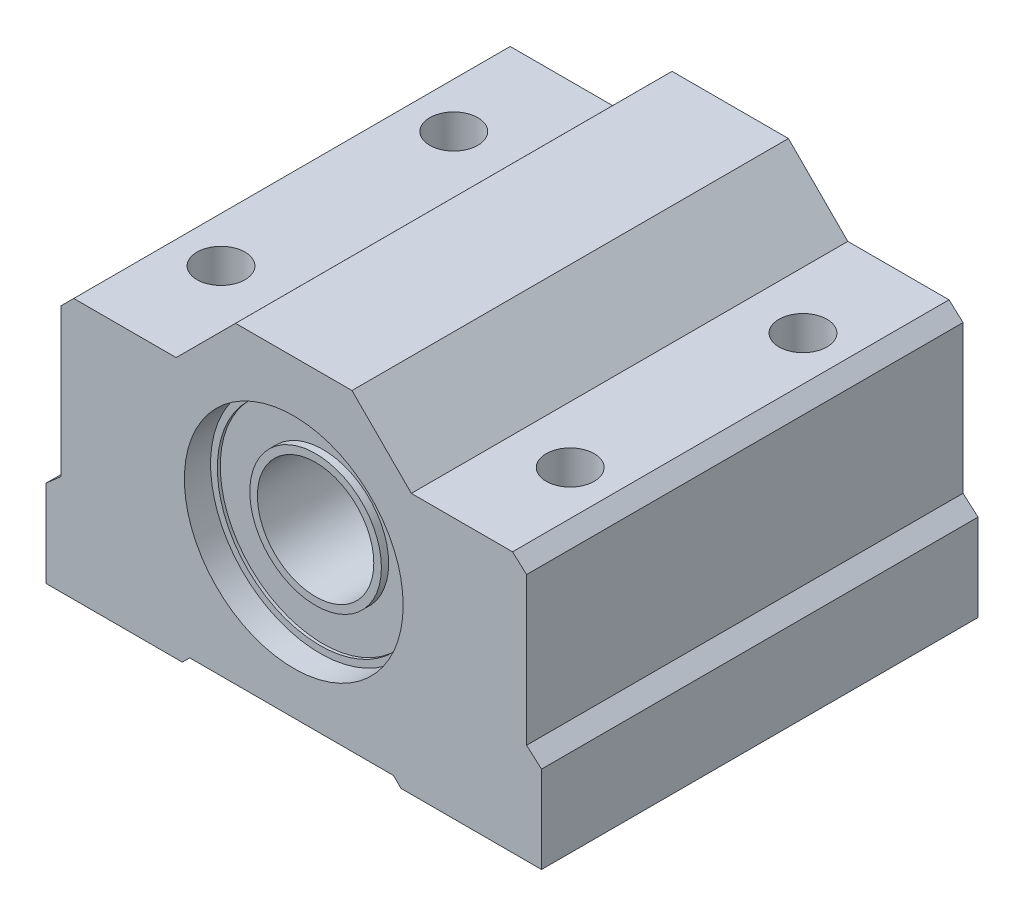
from build123d import *

# Parameters (mm, degrees)
ESQUISSE1_R             = 7.519017315
BOSS_EXTRU_1_DEPTH      = 30
ESQUISSE1_3_R           = 7.051788316
ESQUISSE1_3_R_2         = 4.523392982
BOSS_EXTRU_2_DEPTH      = 28
ESQUISSE1_4_R           = 7.519017315
ESQUISSE1_4_R_2         = 7.051788316
BOSS_EXTRU_3_DEPTH      = 30
ESQUISSE1_5_R           = 4.523392982
ESQUISSE1_5_R_2         = 4
BOSS_EXTRU_4_DEPTH      = 28.5
ESQUISSE1_6_R           = 4.523392982
ESQUISSE1_6_R_2         = 4
ENL_V_MAT_EXTRU_1_DEPTH = 1.5
ESQUISSE1_7_R           = 7.051788316
ESQUISSE1_7_R_2         = 4.523392982
ENL_V_MAT_EXTRU_2_DEPTH = 2
ESQUISSE1_8_R           = 7.519017315
ESQUISSE1_8_R_2         = 7.051788316
ENL_V_MAT_EXTRU_3_DEPTH = 1.8
ENL_V_START             = -30
ESQUISSE1_9_R           = 7.519017315
ESQUISSE1_9_R_2         = 7.051788316
ENL_V_MAT_EXTRU_4_DEPTH = 1.8
ESQUISSE2_R             = 1.65
ENL_V_MAT_EXTRU_5_DEPTH = 21.8


with BuildPart() as part:
    # Esquisse1 → Boss.-Extru.1 (new body)
    with BuildSketch(Plane.XY):
        Polygon((-15.997216081, -4.089203195), (-17.03, -5.004453984), (-17.03, -10.973805396), (-7.66267479, -10.973805396), (-7.153229177, -10.464359784), (6.857616233, -10.464359784), (7.367061846, -10.973805396), (17.03, -10.973805396), (17.03, -4.995255883), (16.002783919, -4.089203195), (16.002783919, 6.07141612), (15.037454618, 6.944265115), (8.081929489, 6.944265115), (4, 11.026194604), (-4, 11.026194604), (-8.083891517, 6.944265115), (-15.124367087, 6.944265115), (-15.997216081, 6.07141612), align=None)
        Circle(ESQUISSE1_R, mode=Mode.SUBTRACT)
    extrude(amount=-BOSS_EXTRU_1_DEPTH)



with BuildPart() as body_2:
    # Esquisse1_3 → Boss.-Extru.2 (new body)
    with BuildSketch(Plane.XY):
        Circle(ESQUISSE1_3_R)
        Circle(ESQUISSE1_3_R_2, mode=Mode.SUBTRACT)
    extrude(amount=-BOSS_EXTRU_2_DEPTH)


with BuildPart() as part_1:
    add(part.part)

    add(body_2.part)  # Boss.-Extru.3 merges body 2
    # Esquisse1_4 → Boss.-Extru.3 (add)
    with BuildSketch(Plane.XY):
        Circle(ESQUISSE1_4_R)
        Circle(ESQUISSE1_4_R_2, mode=Mode.SUBTRACT)
    extrude(amount=-BOSS_EXTRU_3_DEPTH)

    # Esquisse1_5 → Boss.-Extru.4 (add)
    with BuildSketch(Plane.XY):
        Circle(ESQUISSE1_5_R)
        Circle(ESQUISSE1_5_R_2, mode=Mode.SUBTRACT)
    extrude(amount=-BOSS_EXTRU_4_DEPTH)

    # Esquisse1_6 → Enl_v. mat.-Extru.1 (cut)
    with BuildSketch(Plane.XY):
        Circle(ESQUISSE1_6_R)
        Circle(ESQUISSE1_6_R_2, mode=Mode.SUBTRACT)
    extrude(amount=-ENL_V_MAT_EXTRU_1_DEPTH, mode=Mode.SUBTRACT)

    # Esquisse1_7 → Enl_v. mat.-Extru.2 (cut)
    with BuildSketch(Plane.XY):
        Circle(ESQUISSE1_7_R)
        Circle(ESQUISSE1_7_R_2, mode=Mode.SUBTRACT)
    extrude(amount=-ENL_V_MAT_EXTRU_2_DEPTH, mode=Mode.SUBTRACT)

    # Esquisse1_8 → Enl_v. mat.-Extru.3 (cut)
    with BuildSketch(Plane.XY):
        Circle(ESQUISSE1_8_R)
        Circle(ESQUISSE1_8_R_2, mode=Mode.SUBTRACT)
    extrude(amount=-ENL_V_MAT_EXTRU_3_DEPTH, mode=Mode.SUBTRACT)

    # Esquisse1_9 → Enl_v. mat.-Extru.4 (cut)
    with BuildSketch(Plane.XY.offset(ENL_V_START)):
        Circle(ESQUISSE1_9_R)
        Circle(ESQUISSE1_9_R_2, mode=Mode.SUBTRACT)
    extrude(amount=ENL_V_MAT_EXTRU_4_DEPTH, mode=Mode.SUBTRACT)

    # Esquisse2 → Enl_v. mat.-Extru.5 (cut)
    with BuildSketch(Plane.XZ.offset(10.973805396)):
        with Locations((-12, -7)):
            Circle(ESQUISSE2_R)
        with Locations((12, -7)):
            Circle(ESQUISSE2_R)
        with Locations((12, -23)):
            Circle(ESQUISSE2_R)
        with Locations((-12, -23)):
            Circle(ESQUISSE2_R)
    extrude(amount=-ENL_V_MAT_EXTRU_5_DEPTH, mode=Mode.SUBTRACT)


solid = part_1.part
